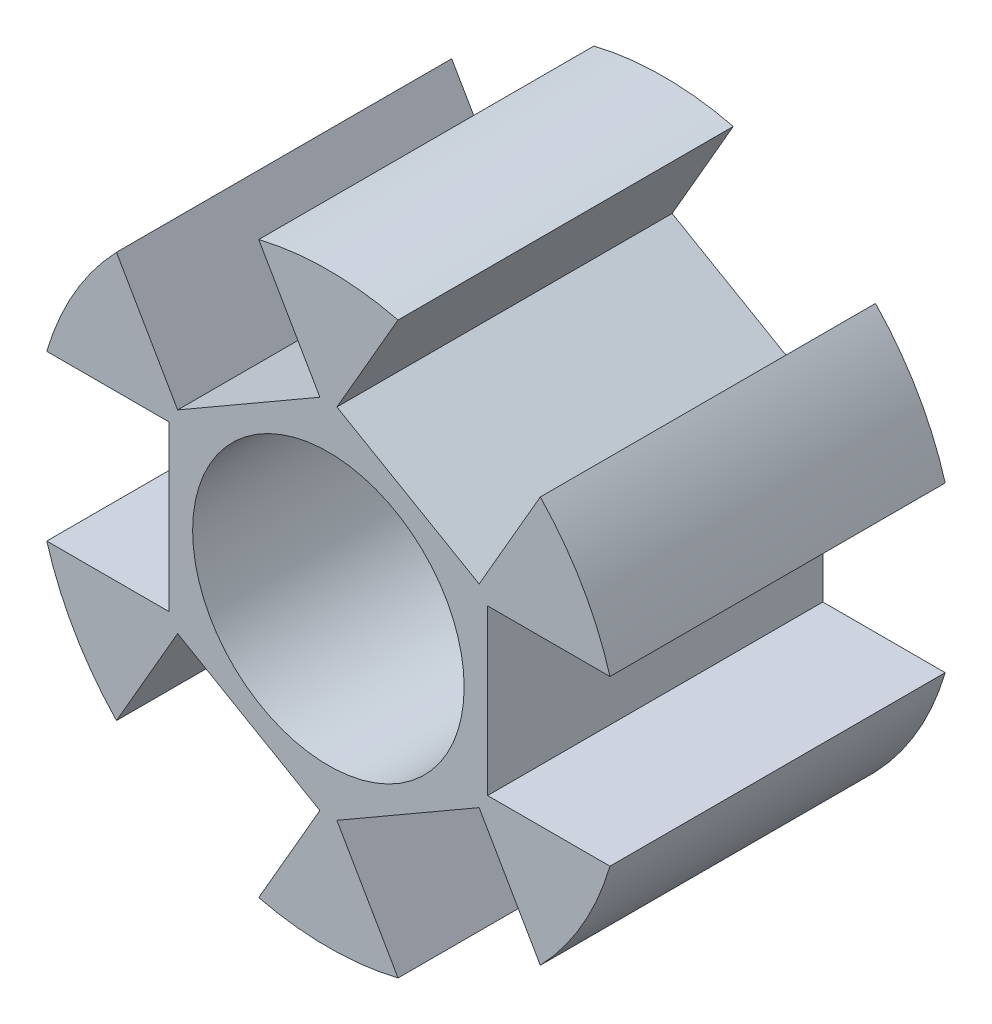
from build123d import *

# Parameters (mm, degrees)
SKETCH1_R           = 8.75
SKETCH1_R_2         = 4.05
BOSS_EXTRUDE1_DEPTH = 5
SKETCH2_W           = 4.9
SKETCH2_H           = 10
CUT_EXTRUDE3_DEPTH  = 4
CIRPATTERN1_COUNT   = 6


with BuildPart() as part:
    # Sketch1 → Boss-Extrude1 (new, symmetric)
    with BuildSketch(Plane.XY):
        Circle(SKETCH1_R)
        Circle(SKETCH1_R_2, mode=Mode.SUBTRACT)
    extrude(amount=BOSS_EXTRUDE1_DEPTH, both=True)

    # Sketch2 → Cut-Extrude3 (cut)
    with BuildSketch(Plane(origin=(-8.75, -17.193061184, 0), x_dir=(0, -1, 0), z_dir=(1, 0, 0))):
        with Locations((-17.193061184, 0)):
            Rectangle(SKETCH2_W, SKETCH2_H)
    cut_extrude3 = extrude(amount=CUT_EXTRUDE3_DEPTH, mode=Mode.SUBTRACT)

    # CirPattern1: Cut-Extrude3 ×6 about axis
    cirpattern1_axis = Axis((0, 0, 5), (0, 0, 1))
    for i in range(1, CIRPATTERN1_COUNT):
        add(cut_extrude3.rotate(cirpattern1_axis, i * 360 / CIRPATTERN1_COUNT), mode=Mode.SUBTRACT)


solid = part.part
